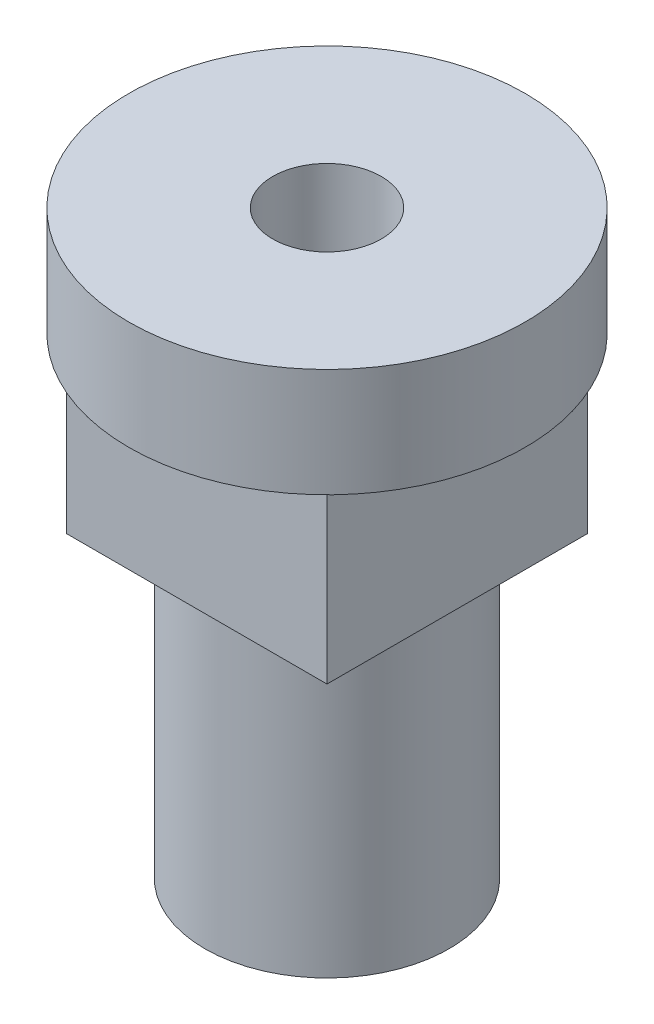
from build123d import *

# Parameters (mm, degrees)
SKETCH1_R           = 4.5
SKETCH1_R_2         = 2
BOSS_EXTRUDE1_DEPTH = 11
BOSS_EXTRUDE2_START = 11
SKETCH1_3_W         = 9.6
SKETCH1_3_H         = 9.6
SKETCH1_3_R         = 4.5
SKETCH1_3_R_2       = 2
BOSS_EXTRUDE2_DEPTH = 6.4
BOSS_EXTRUDE3_START = 17.4
SKETCH1_4_R         = 7.3
SKETCH1_4_W         = 9.6
SKETCH1_4_H         = 9.6
SKETCH1_4_R_2       = 4.5
SKETCH1_4_R_3       = 2
BOSS_EXTRUDE3_DEPTH = 4
CUT_EXTRUDE1_START  = 21.4
SKETCH1_5_R         = 2
CUT_EXTRUDE1_DEPTH  = 10


with BuildPart() as part:
    # Sketch1 → Boss-Extrude1 (new body)
    with BuildSketch(Plane(origin=(0, 0, 0), x_dir=(1, 0, 0), z_dir=(0, 1, 0))):
        Circle(SKETCH1_R)
        Circle(SKETCH1_R_2, mode=Mode.SUBTRACT)
        Circle(SKETCH1_R_2)
    extrude(amount=BOSS_EXTRUDE1_DEPTH)

    # Sketch1_3 → Boss-Extrude2 (add)
    with BuildSketch(Plane(origin=(0, 0, 0), x_dir=(1, 0, 0), z_dir=(0, 1, 0)).offset(BOSS_EXTRUDE2_START)):
        Rectangle(SKETCH1_3_W, SKETCH1_3_H)
        Circle(SKETCH1_3_R, mode=Mode.SUBTRACT)
        Circle(SKETCH1_3_R)
        Circle(SKETCH1_3_R_2, mode=Mode.SUBTRACT)
        Circle(SKETCH1_3_R_2)
    extrude(amount=BOSS_EXTRUDE2_DEPTH)

    # Sketch1_4 → Boss-Extrude3 (add)
    with BuildSketch(Plane(origin=(0, 0, 0), x_dir=(1, 0, 0), z_dir=(0, 1, 0)).offset(BOSS_EXTRUDE3_START)):
        Circle(SKETCH1_4_R)
        Rectangle(SKETCH1_4_W, SKETCH1_4_H, mode=Mode.SUBTRACT)
        Rectangle(SKETCH1_4_W, SKETCH1_4_H)
        Circle(SKETCH1_4_R_2, mode=Mode.SUBTRACT)
        Circle(SKETCH1_4_R_2)
        Circle(SKETCH1_4_R_3, mode=Mode.SUBTRACT)
        Circle(SKETCH1_4_R_3)
    extrude(amount=BOSS_EXTRUDE3_DEPTH)

    # Sketch1_5 → Cut-Extrude1 (cut)
    with BuildSketch(Plane(origin=(0, 0, 0), x_dir=(1, 0, 0), z_dir=(0, 1, 0)).offset(CUT_EXTRUDE1_START)):
        Circle(SKETCH1_5_R)
    extrude(amount=-CUT_EXTRUDE1_DEPTH, mode=Mode.SUBTRACT)


solid = part.part
